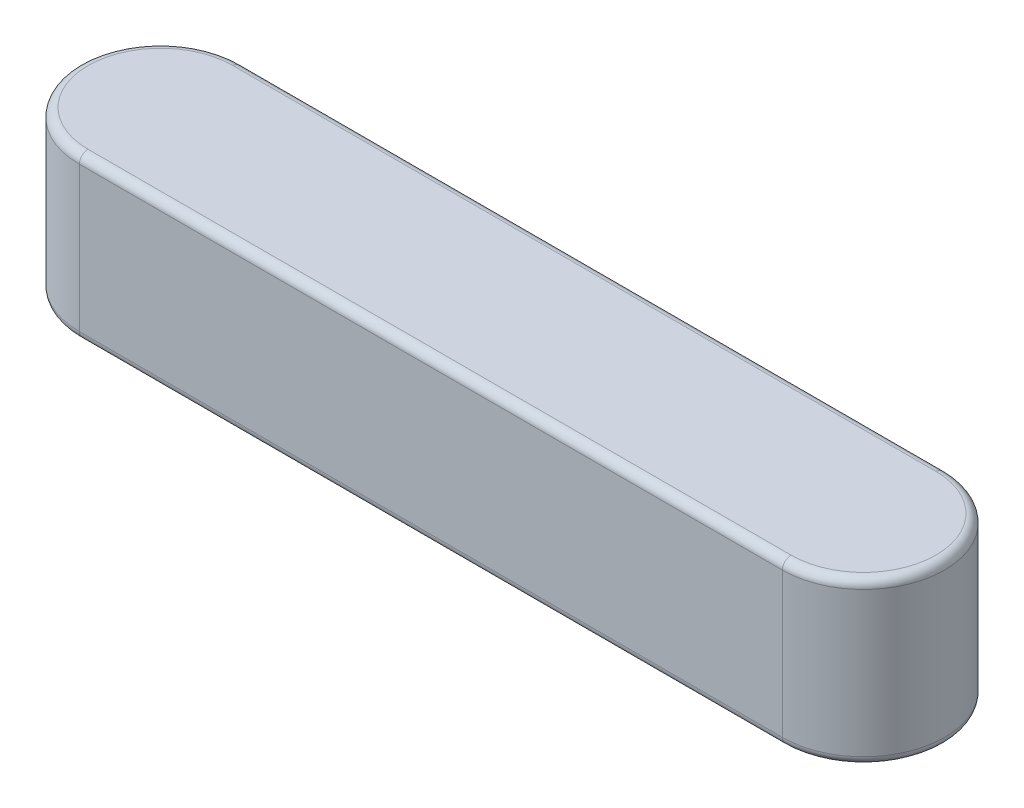
from build123d import *

# Parameters (mm, degrees)
EXTRUDE1_DEPTH = 3
FILLET1_R      = 0.16


with BuildPart() as part:
    # Sketch1 → Extrude1 (new body)
    with BuildSketch(Plane(origin=(0, 0, 0), x_dir=(1, 0, 0), z_dir=(0, 1, 0))):
        with BuildLine():
            Line((-13, 1.5), (0, 1.5))
            ThreePointArc((0, 1.5), (1.5, 0), (0, -1.5))
            Line((0, -1.5), (-13, -1.5))
            ThreePointArc((-13, -1.5), (-14.5, 0), (-13, 1.5))
        make_face()
    extrude(amount=EXTRUDE1_DEPTH)

    # Fillet1
    fillet1_edges = [part.edges().sort_by_distance(p)[0] for p in [
        (1.5, 3, 0),
        (-6.5, 3, -1.5),
        (-14.5, 3, 0),
        (-6.5, 0, -1.5),
        (1.5, 0, 0),
        (-6.5, 0, 1.5),
        (-14.5, 0, 0),
        (-6.5, 3, 1.5),
    ]]
    fillet(fillet1_edges, radius=FILLET1_R)


solid = part.part
